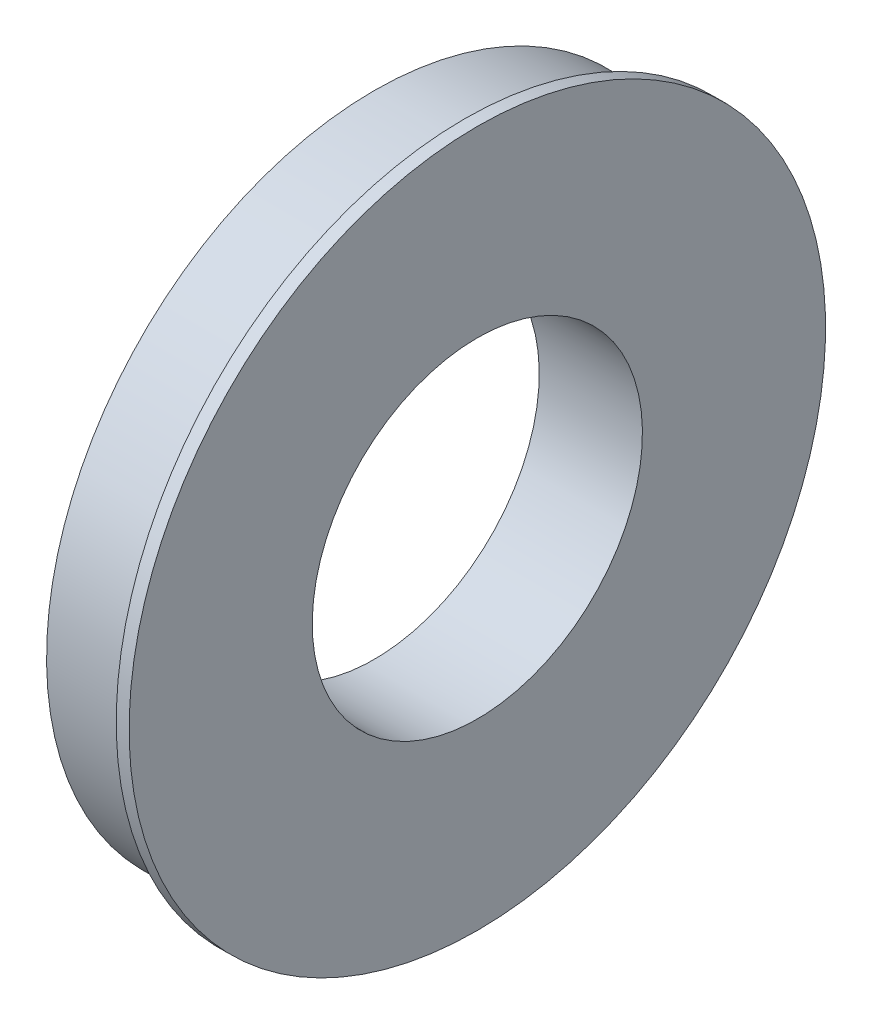
from build123d import *

# Parameters (mm, degrees)
SKETCH2_R          = 32
CUT_EXTRUDE1_DEPTH = 21


with BuildPart() as part:
    # Sketch1 → Revolve1 (revolve)
    with BuildSketch(Plane.XY):
        Polygon((0, 0), (0, 63.5), (17.5, 63.5), (17.5, 67.5), (20, 67.5), (20, 0), align=None)
    revolve(axis=Axis((20, 0, 0), (-1, 0, 0)))

    # Sketch2 → Cut-Extrude1 (cut, through all)
    with BuildSketch(Plane(origin=(20, 0, 0), x_dir=(0, 0, -1), z_dir=(1, 0, 0))):
        Circle(SKETCH2_R)
    extrude(amount=-CUT_EXTRUDE1_DEPTH, mode=Mode.SUBTRACT)


solid = part.part
